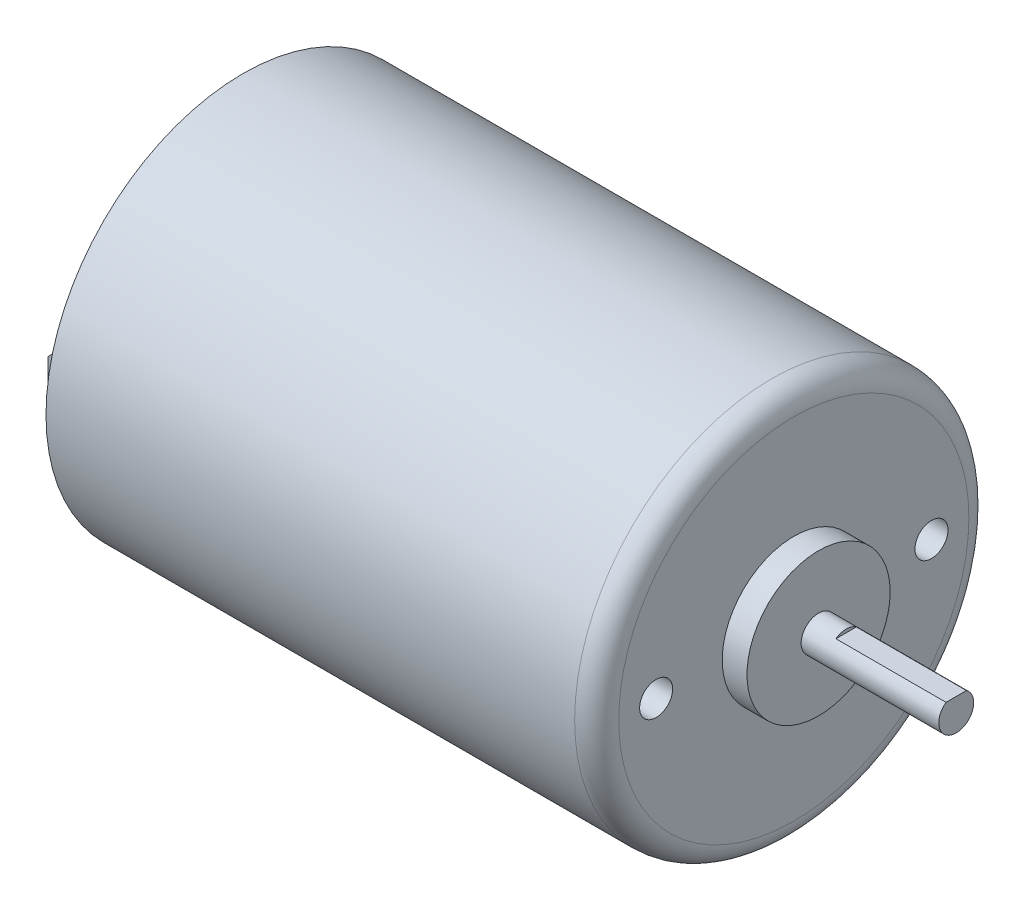
from build123d import *

# Parameters (mm, degrees)
SKETCH1_R           = 17.9
MOTOR_BODY_DEPTH    = 25
SKETCH2_R           = 17.2
CUT_EXTRUDE1_DEPTH  = 0.5
SKETCH3_R           = 12
BOSS_EXTRUDE2_DEPTH = 0.5
SKETCH4_R           = 5.1
BOSS_EXTRUDE3_DEPTH = 1.5
FILLET1_R           = 2
SKETCH5_W           = 0.5
SKETCH5_H           = 4
BOSS_EXTRUDE4_DEPTH = 4
CHAMFER1_SIZE       = 1
SKETCH6_R           = 1.5
MOUNT_HOLES_DEPTH   = 6
SKETCH7_R           = 6.5
BOSS_EXTRUDE5_DEPTH = 2.25
SKETCH8_R           = 1.585
OUTPUT_SHAFT_DEPTH  = 12.5
CUT_EXTRUDE3_DEPTH  = 10


with BuildPart() as part:
    # Sketch1 → Motor-Body (new body, symmetric)
    with BuildSketch(Plane(origin=(0, 0, 0), x_dir=(0, 0, -1), z_dir=(1, 0, 0))):
        Circle(SKETCH1_R)
    extrude(amount=MOTOR_BODY_DEPTH, both=True)

    # Sketch2 → Cut-Extrude1 (cut)
    with BuildSketch(Plane.ZY.offset(25)):
        Circle(SKETCH2_R)
    extrude(amount=-CUT_EXTRUDE1_DEPTH, mode=Mode.SUBTRACT)

    # Sketch3 → Boss-Extrude2 (add, symmetric)
    with BuildSketch(Plane.ZY.offset(24.5)):
        Circle(SKETCH3_R)
    extrude(amount=BOSS_EXTRUDE2_DEPTH, both=True)

    # Sketch4 → Boss-Extrude3 (add, symmetric)
    with BuildSketch(Plane.ZY.offset(25)):
        Circle(SKETCH4_R)
    extrude(amount=BOSS_EXTRUDE3_DEPTH, both=True)

    # Fillet1
    fillet1_edges = [part.edges().sort_by_distance(p)[0] for p in [
        (25, 0, 17.9),
    ]]
    fillet(fillet1_edges, radius=FILLET1_R)

    # Sketch5 → Boss-Extrude4 (add)
    with BuildSketch(Plane.ZY.offset(24.5)):
        with Locations((-13.95, 0)):
            Rectangle(SKETCH5_W, SKETCH5_H)
        with Locations((13.95, 0)):
            Rectangle(SKETCH5_W, SKETCH5_H)
    extrude(amount=BOSS_EXTRUDE4_DEPTH)

    # Chamfer1
    chamfer1_edges = [part.edges().sort_by_distance(p)[0] for p in [
        (-28.5, 2, -13.95),
        (-28.5, -2, -13.95),
        (-28.5, 2, 13.95),
        (-28.5, -2, 13.95),
    ]]
    chamfer(chamfer1_edges, length=CHAMFER1_SIZE)

    # Sketch6 → Mount-Holes (cut)
    with BuildSketch(Plane(origin=(25, 0, 0), x_dir=(0, 0, -1), z_dir=(1, 0, 0))):
        with Locations((-12.5, 0)):
            Circle(SKETCH6_R)
        with Locations((12.5, 0)):
            Circle(SKETCH6_R)
    extrude(amount=-MOUNT_HOLES_DEPTH, mode=Mode.SUBTRACT)

    # Sketch7 → Boss-Extrude5 (add, symmetric)
    with BuildSketch(Plane(origin=(25, 0, 0), x_dir=(0, 0, -1), z_dir=(1, 0, 0))):
        Circle(SKETCH7_R)
    extrude(amount=BOSS_EXTRUDE5_DEPTH, both=True)

    # Sketch8 → Output-Shaft (add)
    with BuildSketch(Plane(origin=(27.25, 0, 0), x_dir=(0, 0, -1), z_dir=(1, 0, 0))):
        Circle(SKETCH8_R)
    extrude(amount=OUTPUT_SHAFT_DEPTH)

    # Sketch9 → Cut-Extrude3 (cut)
    with BuildSketch(Plane(origin=(39.75, 0, 0), x_dir=(0, 0, -1), z_dir=(1, 0, 0))):
        with BuildLine():
            Line((-0.927900857, 1.285), (0.927900857, 1.285))
            ThreePointArc((0.927900857, 1.285), (0, 1.585), (-0.927900857, 1.285))
        make_face()
    extrude(amount=-CUT_EXTRUDE3_DEPTH, mode=Mode.SUBTRACT)


solid = part.part
